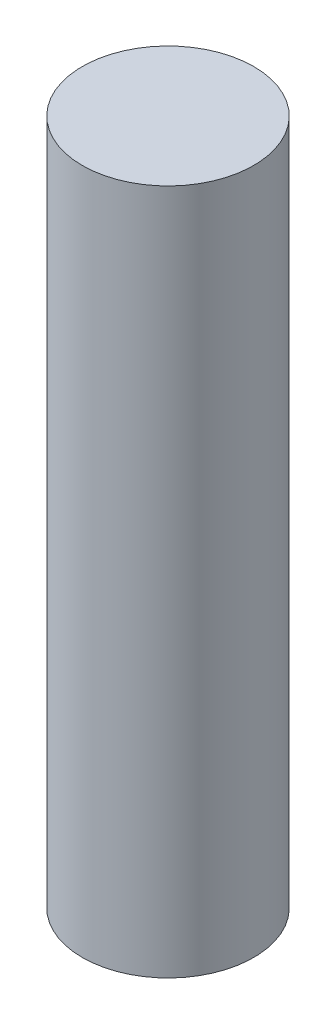
from build123d import *

# Parameters (mm, degrees)
SKETCH1_R           = 6.25
BOSS_EXTRUDE1_DEPTH = 50


with BuildPart() as part:
    # Sketch1 → Boss-Extrude1 (new body)
    with BuildSketch(Plane(origin=(0, 0, 0), x_dir=(1, 0, 0), z_dir=(0, 1, 0))):
        Circle(SKETCH1_R)
    extrude(amount=BOSS_EXTRUDE1_DEPTH)


solid = part.part
